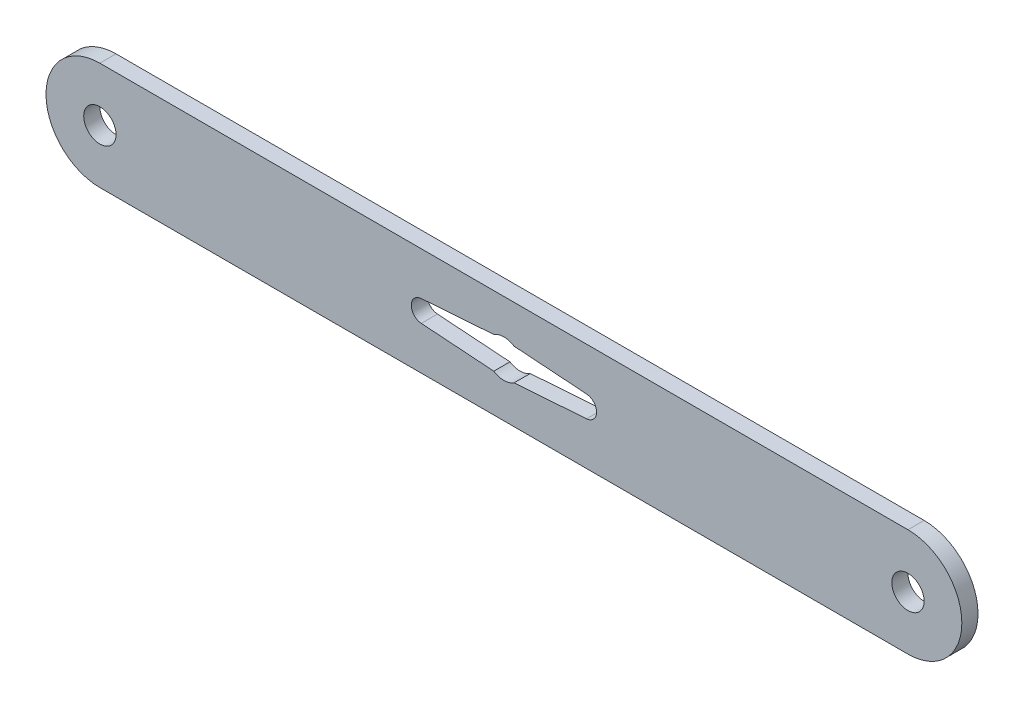
from build123d import *

# Parameters (mm, degrees)
SKETCH1_R           = 3
BOSS_EXTRUDE1_DEPTH = 3


with BuildPart() as part:
    # Sketch1 → Boss-Extrude1 (new body)
    with BuildSketch(Plane.XY):
        with BuildLine():
            Line((75, -10), (-75, -10))
            ThreePointArc((-75, -10), (-85, 0), (-75, 10))
            Line((-75, 10), (75, 10))
            ThreePointArc((75, 10), (85, 0), (75, -10))
        make_face()
        with Locations((75, 0)):
            Circle(SKETCH1_R, mode=Mode.SUBTRACT)
        with Locations((-75, 0)):
            Circle(SKETCH1_R, mode=Mode.SUBTRACT)
        with BuildLine():
            Line((-1.88348082, 2.95), (-15.34156858, 1.994983292))
            ThreePointArc((-15.34156858, 1.994983292), (-17.2, 0), (-15.34156858, -1.994983292))
            Line((-15.34156858, -1.994983292), (-1.88348082, -2.95))
            ThreePointArc((-1.88348082, -2.95), (0, -3.5), (1.88348082, -2.95))
            Line((1.88348082, -2.95), (15.34156858, -1.994983292))
            ThreePointArc((15.34156858, -1.994983292), (17.2, 0), (15.34156858, 1.994983292))
            Line((15.34156858, 1.994983292), (1.88348082, 2.95))
            ThreePointArc((1.88348082, 2.95), (0, 3.5), (-1.88348082, 2.95))
        make_face(mode=Mode.SUBTRACT)
    extrude(amount=BOSS_EXTRUDE1_DEPTH)


solid = part.part
